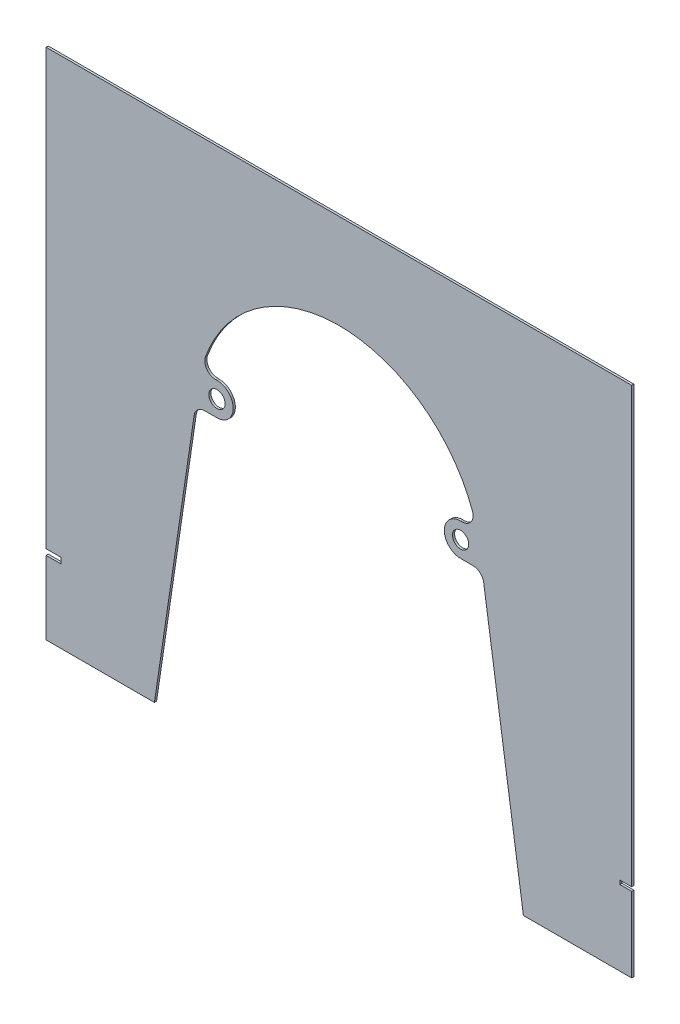
from build123d import *

# Parameters (mm, degrees)
SKETCH1_R           = 9.592533987
SKETCH1_R_2         = 9.525
BOSS_EXTRUDE1_DEPTH = 2.54


with BuildPart() as part:
    # Sketch1 → Boss-Extrude1 (new body)
    with BuildSketch(Plane.XY):
        with BuildLine():
            Line((325.101849056, -276.74558404), (325.101849056, -188.761052666))
            Line((325.101849056, -188.761052666), (311.147367129, -188.761052666))
            Line((311.147367129, -188.761052666), (311.147367129, -184.170327252))
            Line((311.147367129, -184.170327252), (325.101849056, -184.170327252))
            Line((325.101849056, -184.170327252), (325.101849056, 325.138013642))
            Line((325.101849056, 325.138013642), (-361.55061518, 325.138013642))
            Line((-361.55061518, 325.138013642), (-361.55061518, -184.170327252))
            Line((-361.55061518, -184.170327252), (-344.367661442, -184.170327252))
            Line((-344.367661442, -184.170327252), (-344.367661442, -190.835742865))
            Line((-344.367661442, -190.835742865), (-361.55061518, -190.835742865))
            Line((-361.55061518, -190.835742865), (-361.55061518, -276.74558404))
            Line((-361.55061518, -276.74558404), (-234.55061518, -276.74558404))
            add(Edge.make_bspline(
                [(-187.980509507, 38.133773771), (-188.27489671, 36.13210674), (-188.569257118, 34.130435751), (-190.3693668, 21.889980342), (-191.876305024, 11.651371561), (-196.404427488, -19.063375229), (-199.428229196, -39.539126569), (-205.483427481, -80.489507286), (-208.515826842, -100.963988527), (-219.215042163, -173.207603441), (-226.881928481, -224.976726722), (-234.55061518, -276.74558404)],
                knots=[0.775140665, 0.775140665, 0.775140665, 0.775140665, 0.78125, 0.78125, 0.8125, 0.8125, 0.875, 0.875, 0.9375, 0.9375, 1.095529214, 1.095529214, 1.095529214, 1.095529214], degree=3))
            ThreePointArc((-187.980509507, 38.133773771), (-183.716916528, 45.897266013), (-175.41567054, 48.985850142))
            Line((-175.41567054, 48.985850142), (-161.253773138, 48.985850142))
            ThreePointArc((-161.253773138, 48.985850142), (-142.203773138, 68.035850142), (-161.253773138, 87.085850141))
            Line((-161.253773138, 87.085850141), (-162.853778681, 87.085850141))
            ThreePointArc((-162.853778681, 87.085850141), (-173.256071513, 92.500089794), (-174.788993269, 104.126432214))
            add(Edge.make_bspline(
                [(138.340023196, 104.1264177), (138.155537808, 104.633695525), (137.968537838, 105.140328765), (136.878523505, 108.050508672), (135.441958767, 111.634797813), (133.873557403, 115.185292105), (132.798253571, 117.544674285), (132.244938124, 118.72221102), (129.414540718, 124.567063869), (126.94937257, 129.101743153), (121.630471343, 137.897930344), (118.776746577, 142.159444094), (112.686474548, 150.413337301), (107.831924529, 156.402096918), (102.540177193, 162.083495309), (99.819602382, 164.871677634), (98.900271279, 165.792240869), (97.046227751, 167.606080988), (96.110329243, 168.500592287), (91.386634358, 172.911358508), (87.466457166, 176.242558862), (79.351868776, 182.521609038), (75.1575089, 185.469530602), (66.495709426, 190.983636766), (62.02828952, 193.549848892), (55.115179884, 197.102841468), (52.770906129, 198.23944579), (48.057920232, 200.390162802), (45.684402026, 201.406997485), (38.513619271, 204.284843788), (33.666257106, 205.973646323), (23.839984133, 208.89905679), (18.861006507, 210.13543504), (11.293001851, 211.647842714), (8.753729317, 212.094901761), (4.919604431, 212.678810774), (3.63735506, 212.858983123), (1.064351829, 213.190093886), (-0.227403309, 213.341124006), (-4.104657388, 213.748796074), (-6.69392087, 213.960280793), (-10.584377098, 214.188154302), (-11.882288513, 214.24923116), (-14.480247284, 214.34229574), (-15.77998427, 214.375695042), (-18.379751713, 214.405675513), (-19.679864546, 214.392033292), (-22.279014783, 214.333304532), (-23.578445595, 214.289247872), (-27.473045877, 214.113425657), (-30.064936685, 213.93719921), (-35.239513244, 213.464285113), (-37.82599866, 213.167115032), (-42.960254521, 212.456338993), (-45.510284017, 212.042773536), (-53.109929228, 210.630443886), (-58.109124925, 209.46012554), (-67.974579463, 206.667171099), (-72.840887694, 205.044703051), (-80.039629101, 202.268297913), (-83.613765485, 200.794235552), (-87.149475357, 199.189426954), (-89.497993793, 198.090219969), (-90.669429689, 197.525202002), (-96.484812077, 194.636054099), (-100.994154698, 192.125739674), (-109.738071064, 186.722649456), (-113.972669304, 183.829907758), (-122.167753951, 177.662877555), (-126.128054678, 174.388330596), (-131.857503737, 169.182808313), (-133.731998876, 167.398469262), (-136.490242047, 164.64749262), (-137.400625577, 163.718129876), (-139.194142166, 161.84440698), (-140.078494423, 160.898848159), (-144.439064905, 156.128155654), (-147.732037091, 152.174555571), (-153.934907403, 143.998797648), (-156.844744983, 139.776597363), (-162.276947412, 131.060555304), (-164.799263726, 126.566679506), (-168.283130528, 119.615822968), (-169.395978502, 117.259661658), (-171.499158951, 112.524180704), (-172.492247577, 110.139827958), (-173.895945336, 106.538995231), (-174.349562031, 105.334727793), (-174.788993269, 104.126432214)],
                knots=[0.295230777, 0.295230777, 0.295230777, 0.295230777, 0.296875, 0.296875, 0.3046875, 0.30859375, 0.30859375, 0.3125, 0.3125, 0.328125, 0.328125, 0.34375, 0.34375, 0.359375, 0.3671875, 0.3671875, 0.37109375, 0.37109375, 0.375, 0.375, 0.390625, 0.390625, 0.40625, 0.40625, 0.421875, 0.421875, 0.4296875, 0.4296875, 0.4375, 0.4375, 0.453125, 0.453125, 0.46875, 0.46875, 0.4765625, 0.4765625, 0.48046875, 0.48046875, 0.484375, 0.484375, 0.4921875, 0.4921875, 0.49609375, 0.49609375, 0.5, 0.5, 0.50390625, 0.50390625, 0.5078125, 0.5078125, 0.515625, 0.515625, 0.5234375, 0.5234375, 0.53125, 0.53125, 0.546875, 0.546875, 0.5625, 0.5625, 0.5703125, 0.57421875, 0.57421875, 0.578125, 0.578125, 0.59375, 0.59375, 0.609375, 0.609375, 0.625, 0.625, 0.6328125, 0.6328125, 0.63671875, 0.63671875, 0.640625, 0.640625, 0.65625, 0.65625, 0.671875, 0.671875, 0.6875, 0.6875, 0.6953125, 0.6953125, 0.703125, 0.703125, 0.707030961, 0.707030961, 0.707030961, 0.707030961], degree=3))
            ThreePointArc((138.340023196, 104.1264177), (136.807091731, 92.500083469), (126.404803329, 87.085850141))
            Line((126.404803329, 87.085850141), (124.418789558, 87.085850141))
            ThreePointArc((124.418789558, 87.085850141), (105.368789558, 68.035850142), (124.418789558, 48.985850142))
            Line((124.418789558, 48.985850142), (138.966782744, 48.985850142))
            ThreePointArc((138.966782744, 48.985850142), (147.268029336, 45.897265491), (151.531621943, 38.133772192))
            add(Edge.make_bspline(
                [(198.101849056, -276.74558404), (190.457207742, -225.140201219), (182.814584349, -173.534519662), (172.163765006, -101.617813639), (169.155561459, -81.306790297), (163.148374331, -40.683378675), (160.148663276, -20.371098521), (155.656220674, 10.098370509), (154.16095032, 20.255186016), (152.288653907, 32.986071489), (151.910159921, 35.559925083), (151.531621943, 38.133772192)],
                knots=[-0.096298018, -0.096298018, -0.096298018, -0.096298018, 0.0625, 0.0625, 0.125, 0.125, 0.1875, 0.1875, 0.21875, 0.21875, 0.22666892, 0.22666892, 0.22666892, 0.22666892], degree=3))
            Line((198.101849056, -276.74558404), (325.101849056, -276.74558404))
        make_face()
        with Locations((-161.253773138, 68.035850142)):
            Circle(SKETCH1_R, mode=Mode.SUBTRACT)
        with Locations((124.418789558, 68.035850142)):
            Circle(SKETCH1_R_2, mode=Mode.SUBTRACT)
    extrude(amount=BOSS_EXTRUDE1_DEPTH)


solid = part.part
